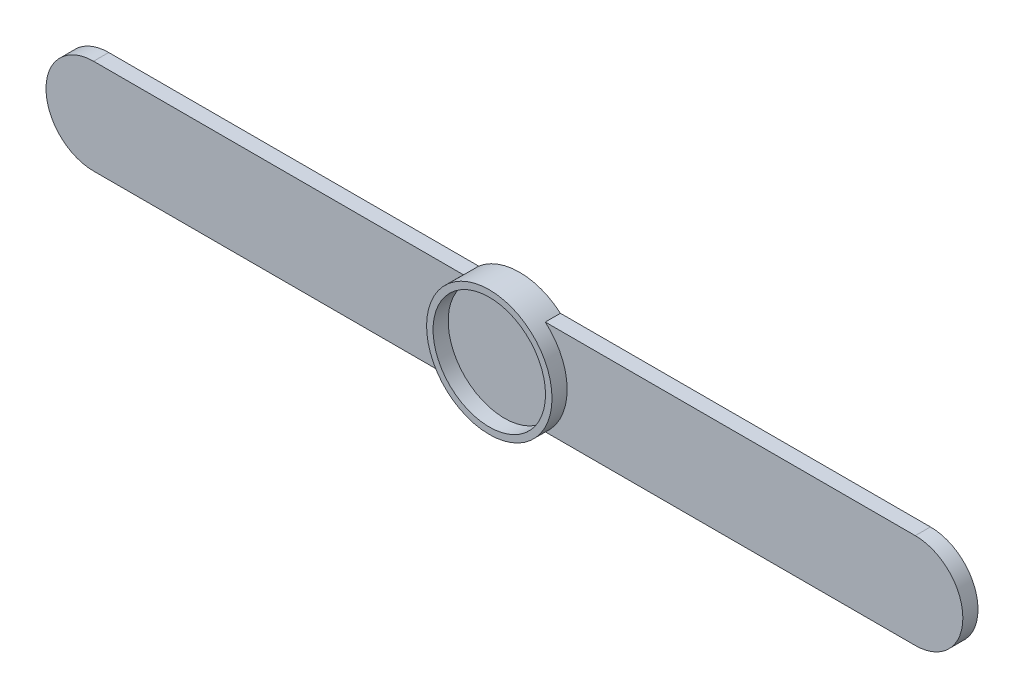
from build123d import *

# Parameters (mm, degrees)
SKETCH_3_R      = 14.5
SKETCH_3_R_2    = 11
SKETCH_3_W      = 190
SKETCH_3_H      = 22
EXTRUDE_2_DEPTH = 3.5
SKETCH_5_R      = 14.5
SKETCH_5_R_2    = 13
EXTRUDE_3_DEPTH = 3.5


with BuildPart() as part:
    # Эскиз3 → Бобышка-Вытянуть2 (new body)
    with BuildSketch(Plane.XY):
        Circle(SKETCH_3_R)
        with Locations((-95, 0)):
            Circle(SKETCH_3_R_2)
        with Locations((95, 0)):
            Circle(SKETCH_3_R_2)
        Rectangle(SKETCH_3_W, SKETCH_3_H)
    extrude(amount=EXTRUDE_2_DEPTH)

    # Эскиз5 → Бобышка-Вытянуть3 (add)
    with BuildSketch(Plane.XY.offset(3.5)):
        Circle(SKETCH_5_R)
        Circle(SKETCH_5_R_2, mode=Mode.SUBTRACT)
    extrude(amount=EXTRUDE_3_DEPTH)


solid = part.part
